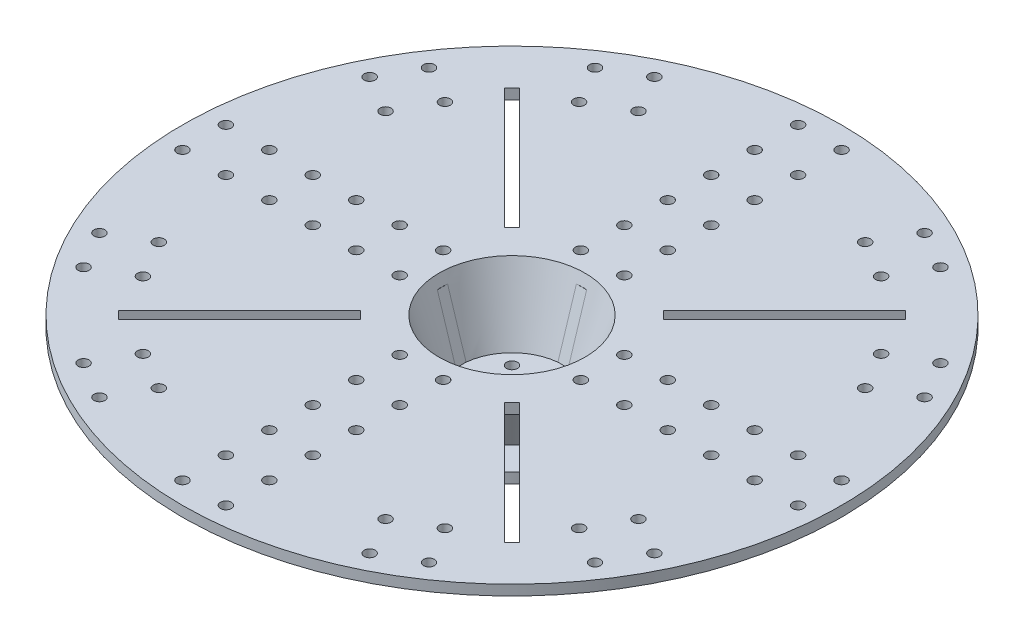
from build123d import *

# Parameters (mm, degrees)
BOSS_EXTRUDE2_DEPTH          = 3
CIRPATTERN2_COUNT            = 4
CUT_EXTRUDE3_DEPTH           = 6
CIRPATTERN4_COUNT            = 4
SKETCH7_W                    = 6
SKETCH7_H                    = 6
CUT_EXTRUDE4_DEPTH           = 34.25
SKETCH8_R                    = 3.175
CUT_EXTRUDE5_DEPTH           = 276.405074148
SKETCH11_R                   = 3.2
CUT_EXTRUDE6_DEPTH           = 276.405074148
LPATTERN2_COUNT              = 2
LPATTERN2_PITCH              = 25.4
LPATTERN2_COUNT_DIR2         = 6
LPATTERN2_PITCH_DIR2         = 25.4
CIRPATTERN5_COUNT            = 4
CIRPATTERN5_COPY_1_SKETCH_R  = 3.2
CIRPATTERN5_COPY_1_DEPTH     = 276.405074148
CIRPATTERN5_COPY_2_SKETCH_R  = 3.2
CIRPATTERN5_COPY_2_DEPTH     = 276.405074148
CIRPATTERN5_COPY_3_SKETCH_R  = 3.2
CIRPATTERN5_COPY_3_DEPTH     = 276.405074148
CIRPATTERN5_COPY_4_SKETCH_R  = 3.2
CIRPATTERN5_COPY_4_DEPTH     = 276.405074148
CIRPATTERN5_COPY_5_SKETCH_R  = 3.2
CIRPATTERN5_COPY_5_DEPTH     = 276.405074148
CIRPATTERN5_COPY_6_SKETCH_R  = 3.2
CIRPATTERN5_COPY_6_DEPTH     = 276.405074148
CIRPATTERN5_COPY_7_SKETCH_R  = 3.2
CIRPATTERN5_COPY_7_DEPTH     = 276.405074148
CIRPATTERN5_COPY_8_SKETCH_R  = 3.2
CIRPATTERN5_COPY_8_DEPTH     = 276.405074148
CIRPATTERN5_COPY_9_SKETCH_R  = 3.2
CIRPATTERN5_COPY_9_DEPTH     = 276.405074148
CIRPATTERN5_COPY_10_SKETCH_R = 3.2
CIRPATTERN5_COPY_10_DEPTH    = 276.405074148
CIRPATTERN5_COPY_11_SKETCH_R = 3.2
CIRPATTERN5_COPY_11_DEPTH    = 276.405074148
CIRPATTERN5_COPY_12_SKETCH_R = 3.2
CIRPATTERN5_COPY_12_DEPTH    = 276.405074148
CIRPATTERN5_COPY_13_SKETCH_R = 3.2
CIRPATTERN5_COPY_13_DEPTH    = 276.405074148
CIRPATTERN5_COPY_14_SKETCH_R = 3.2
CIRPATTERN5_COPY_14_DEPTH    = 276.405074148
CIRPATTERN5_COPY_15_SKETCH_R = 3.2
CIRPATTERN5_COPY_15_DEPTH    = 276.405074148
CIRPATTERN5_COPY_16_SKETCH_R = 3.2
CIRPATTERN5_COPY_16_DEPTH    = 276.405074148
CIRPATTERN5_COPY_17_SKETCH_R = 3.2
CIRPATTERN5_COPY_17_DEPTH    = 276.405074148
CIRPATTERN5_COPY_18_SKETCH_R = 3.2
CIRPATTERN5_COPY_18_DEPTH    = 276.405074148
CIRPATTERN5_COPY_19_SKETCH_R = 3.2
CIRPATTERN5_COPY_19_DEPTH    = 276.405074148
CIRPATTERN5_COPY_20_SKETCH_R = 3.2
CIRPATTERN5_COPY_20_DEPTH    = 276.405074148
CIRPATTERN5_COPY_21_SKETCH_R = 3.2
CIRPATTERN5_COPY_21_DEPTH    = 276.405074148
CIRPATTERN5_COPY_22_SKETCH_R = 3.2
CIRPATTERN5_COPY_22_DEPTH    = 276.405074148
CIRPATTERN5_COPY_23_SKETCH_R = 3.2
CIRPATTERN5_COPY_23_DEPTH    = 276.405074148
CIRPATTERN5_COPY_24_SKETCH_R = 3.2
CIRPATTERN5_COPY_24_DEPTH    = 276.405074148
CIRPATTERN5_COPY_25_SKETCH_R = 3.2
CIRPATTERN5_COPY_25_DEPTH    = 276.405074148
CIRPATTERN5_COPY_26_SKETCH_R = 3.2
CIRPATTERN5_COPY_26_DEPTH    = 276.405074148
CIRPATTERN5_COPY_27_SKETCH_R = 3.2
CIRPATTERN5_COPY_27_DEPTH    = 276.405074148
CIRPATTERN5_COPY_28_SKETCH_R = 3.2
CIRPATTERN5_COPY_28_DEPTH    = 276.405074148
CIRPATTERN5_COPY_29_SKETCH_R = 3.2
CIRPATTERN5_COPY_29_DEPTH    = 276.405074148
CIRPATTERN5_COPY_30_SKETCH_R = 3.2
CIRPATTERN5_COPY_30_DEPTH    = 276.405074148
CIRPATTERN5_COPY_31_SKETCH_R = 3.2
CIRPATTERN5_COPY_31_DEPTH    = 276.405074148
CIRPATTERN5_COPY_32_SKETCH_R = 3.2
CIRPATTERN5_COPY_32_DEPTH    = 276.405074148
CIRPATTERN5_COPY_33_SKETCH_R = 3.2
CIRPATTERN5_COPY_33_DEPTH    = 276.405074148
SKETCH17_R                   = 3.2
CUT_EXTRUDE7_DEPTH           = 277.345716208
LPATTERN3_COUNT              = 2
LPATTERN3_PITCH              = 25.4
LPATTERN3_COUNT_DIR2         = 2
LPATTERN3_PITCH_DIR2         = 25.4
MIRROR1_COPY_1_SKETCH_R      = 3.2
MIRROR1_COPY_1_DEPTH         = 277.345716208
MIRROR1_COPY_2_SKETCH_R      = 3.2
MIRROR1_COPY_2_DEPTH         = 277.345716208
MIRROR1_COPY_3_SKETCH_R      = 3.2
MIRROR1_COPY_3_DEPTH         = 277.345716208
MIRROR2_COPY_1_SKETCH_R      = 3.2
MIRROR2_COPY_1_DEPTH         = 277.345716208
MIRROR2_COPY_2_SKETCH_R      = 3.2
MIRROR2_COPY_2_DEPTH         = 277.345716208
MIRROR2_COPY_3_SKETCH_R      = 3.2
MIRROR2_COPY_3_DEPTH         = 277.345716208
MIRROR2_COPY_4_SKETCH_R      = 3.2
MIRROR2_COPY_4_DEPTH         = 277.345716208
MIRROR2_COPY_5_SKETCH_R      = 3.2
MIRROR2_COPY_5_DEPTH         = 277.345716208
MIRROR2_COPY_6_SKETCH_R      = 3.2
MIRROR2_COPY_6_DEPTH         = 277.345716208
MIRROR2_COPY_7_SKETCH_R      = 3.2
MIRROR2_COPY_7_DEPTH         = 277.345716208
CUT_EXTRUDE8_REACH           = 278.346
CIRPATTERN6_COUNT            = 4
SKETCH23_R                   = 3.2
CUT_EXTRUDE9_DEPTH           = 5.952869
CIRPATTERN7_COUNT            = 2
CIRPATTERN7_ANGLE            = 30
CIRPATTERN8_COUNT            = 4
CIRPATTERN8_COPY_1_SKETCH_R  = 3.2
CIRPATTERN8_COPY_1_DEPTH     = 5.952869
CIRPATTERN8_COPY_2_SKETCH_R  = 3.2
CIRPATTERN8_COPY_2_DEPTH     = 5.952869
CIRPATTERN8_COPY_3_SKETCH_R  = 3.2
CIRPATTERN8_COPY_3_DEPTH     = 5.952869
SKETCH26_R                   = 3.2
CUT_EXTRUDE10_DEPTH          = 277.345716208
LPATTERN4_COUNT              = 2
LPATTERN4_PITCH              = 25.4
LPATTERN4_COUNT_DIR2         = 2
LPATTERN4_PITCH_DIR2         = 25.4
MIRROR3_COPY_1_SKETCH_R      = 3.2
MIRROR3_COPY_1_DEPTH         = 277.345716208
MIRROR3_COPY_2_SKETCH_R      = 3.2
MIRROR3_COPY_2_DEPTH         = 277.345716208
MIRROR3_COPY_3_SKETCH_R      = 3.2
MIRROR3_COPY_3_DEPTH         = 277.345716208
MIRROR4_COPY_1_SKETCH_R      = 3.2
MIRROR4_COPY_1_DEPTH         = 277.345716208
MIRROR4_COPY_2_SKETCH_R      = 3.2
MIRROR4_COPY_2_DEPTH         = 277.345716208
MIRROR4_COPY_3_SKETCH_R      = 3.2
MIRROR4_COPY_3_DEPTH         = 277.345716208
MIRROR4_COPY_4_SKETCH_R      = 3.2
MIRROR4_COPY_4_DEPTH         = 277.345716208
MIRROR4_COPY_5_SKETCH_R      = 3.2
MIRROR4_COPY_5_DEPTH         = 277.345716208
MIRROR4_COPY_6_SKETCH_R      = 3.2
MIRROR4_COPY_6_DEPTH         = 277.345716208
MIRROR4_COPY_7_SKETCH_R      = 3.2
MIRROR4_COPY_7_DEPTH         = 277.345716208
CUT_EXTRUDE11_REACH          = 278.346
SKETCH27_R                   = 3.2
CIRPATTERN9_COUNT            = 4
CUT_EXTRUDE12_REACH          = 280.445
SKETCH28_W                   = 56
SKETCH28_H                   = 6.4
CIRPATTERN10_COUNT           = 4


with BuildPart() as part:
    # Sketch1 → Revolve2 (revolve)
    with BuildSketch(Plane.XY, mode=Mode.PRIVATE) as revolve2_sk:
        Polygon((0, -40.25), (0, -46.25), (55.5, -46.25), (55.5, -40.29713119), (36.117911549, -40.29713119), (46.896841146, -6), (192.649801929, -6), (192.649801929, 0), (42.649801929, 0), (30, -40.25), align=None)
    revolve(revolve2_sk.sketch.rotate(Axis((0, -40.25, 0), (0, -1, 0)), 90), axis=Axis((0, -40.25, 0), (0, -1, 0)))

    # Sketch3 → Boss-Extrude2 (add, symmetric)
    with BuildSketch(Plane.XY):
        Polygon((55.5, -40.29713119), (192.649801929, -6), (0, -6), (0, -40.29713119), align=None)
    boss_extrude2 = extrude(amount=BOSS_EXTRUDE2_DEPTH, both=True)

    # CirPattern2: Boss-Extrude2 ×4 about axis
    cirpattern2_axis = Axis((0, 0, 0), (0, 1, 0))
    for i in range(1, CIRPATTERN2_COUNT):
        add(boss_extrude2.rotate(cirpattern2_axis, i * 360 / CIRPATTERN2_COUNT))

    # Sketch6 → Cut-Extrude3 (cut)
    with BuildSketch(Plane.XY.offset(3)):
        Polygon((-3, -6), (-40.653576086, -6), (-29.849623113, -40.25), (-3, -40.25), align=None)
    cut_extrude3 = extrude(amount=-CUT_EXTRUDE3_DEPTH, mode=Mode.SUBTRACT)

    # CirPattern4: Cut-Extrude3 ×4 about axis
    cirpattern4_axis = Axis((0, 0, 0), (0, 1, 0))
    for i in range(1, CIRPATTERN4_COUNT):
        add(cut_extrude3.rotate(cirpattern4_axis, i * 360 / CIRPATTERN4_COUNT), mode=Mode.SUBTRACT)

    # Sketch7 → Cut-Extrude4 (cut)
    with BuildSketch(Plane(origin=(0, -6, 0), x_dir=(1, 0, 0), z_dir=(0, 1, 0))):
        Rectangle(SKETCH7_W, SKETCH7_H)
    extrude(amount=-CUT_EXTRUDE4_DEPTH, mode=Mode.SUBTRACT)

    # Sketch8 → Cut-Extrude5 (cut, through all)
    with BuildSketch(Plane(origin=(0, -40.25, 0), x_dir=(1, 0, 0), z_dir=(0, 1, 0))):
        with Locations(Location((0, 0, 0), (0, 0, 180))):
            Circle(SKETCH8_R)
    extrude(amount=-CUT_EXTRUDE5_DEPTH, mode=Mode.SUBTRACT)

    # Sketch11 → Cut-Extrude6 (cut, through all)
    with BuildSketch(Plane.XZ.offset(6)):
        with Locations((-12.7, 179.949801929)):
            Circle(SKETCH11_R)
    cut_extrude6 = extrude(amount=-CUT_EXTRUDE6_DEPTH, mode=Mode.SUBTRACT)

    # LPattern2: Cut-Extrude6 2 × 6
    with Locations(*[(i * LPATTERN2_PITCH, 0, -j * LPATTERN2_PITCH_DIR2) for i in range(LPATTERN2_COUNT) for j in range(LPATTERN2_COUNT_DIR2) if (i, j) != (0, 0)]):
        add(cut_extrude6, mode=Mode.SUBTRACT)

    # CirPattern5: Cut-Extrude6 ×4 about axis
    cirpattern5_axis = Axis((0, 0, 0), (0, 1, 0))
    for i in range(1, CIRPATTERN5_COUNT):
        add(cut_extrude6.rotate(cirpattern5_axis, i * 360 / CIRPATTERN5_COUNT), mode=Mode.SUBTRACT)

    # CirPattern5 copy 1 sketch → CirPattern5 copy 1 (cut, through all)
    with BuildSketch(Plane(origin=(-25.4, -6, 0), x_dir=(0, 0, -1), z_dir=(0, -1, 0))):
        with Locations((-12.7, 179.949801929)):
            Circle(CIRPATTERN5_COPY_1_SKETCH_R)
    extrude(amount=-CIRPATTERN5_COPY_1_DEPTH, mode=Mode.SUBTRACT)

    # CirPattern5 copy 2 sketch → CirPattern5 copy 2 (cut, through all)
    with BuildSketch(Plane(origin=(0, -6, 25.4), x_dir=(-1, 0, 0), z_dir=(0, -1, 0))):
        with Locations((-12.7, 179.949801929)):
            Circle(CIRPATTERN5_COPY_2_SKETCH_R)
    extrude(amount=-CIRPATTERN5_COPY_2_DEPTH, mode=Mode.SUBTRACT)

    # CirPattern5 copy 3 sketch → CirPattern5 copy 3 (cut, through all)
    with BuildSketch(Plane(origin=(25.4, -6, 0), x_dir=(0, 0, 1), z_dir=(0, -1, 0))):
        with Locations((-12.7, 179.949801929)):
            Circle(CIRPATTERN5_COPY_3_SKETCH_R)
    extrude(amount=-CIRPATTERN5_COPY_3_DEPTH, mode=Mode.SUBTRACT)

    # CirPattern5 copy 4 sketch → CirPattern5 copy 4 (cut, through all)
    with BuildSketch(Plane(origin=(-50.8, -6, 0), x_dir=(0, 0, -1), z_dir=(0, -1, 0))):
        with Locations((-12.7, 179.949801929)):
            Circle(CIRPATTERN5_COPY_4_SKETCH_R)
    extrude(amount=-CIRPATTERN5_COPY_4_DEPTH, mode=Mode.SUBTRACT)

    # CirPattern5 copy 5 sketch → CirPattern5 copy 5 (cut, through all)
    with BuildSketch(Plane(origin=(0, -6, 50.8), x_dir=(-1, 0, 0), z_dir=(0, -1, 0))):
        with Locations((-12.7, 179.949801929)):
            Circle(CIRPATTERN5_COPY_5_SKETCH_R)
    extrude(amount=-CIRPATTERN5_COPY_5_DEPTH, mode=Mode.SUBTRACT)

    # CirPattern5 copy 6 sketch → CirPattern5 copy 6 (cut, through all)
    with BuildSketch(Plane(origin=(50.8, -6, 0), x_dir=(0, 0, 1), z_dir=(0, -1, 0))):
        with Locations((-12.7, 179.949801929)):
            Circle(CIRPATTERN5_COPY_6_SKETCH_R)
    extrude(amount=-CIRPATTERN5_COPY_6_DEPTH, mode=Mode.SUBTRACT)

    # CirPattern5 copy 7 sketch → CirPattern5 copy 7 (cut, through all)
    with BuildSketch(Plane(origin=(-76.2, -6, 0), x_dir=(0, 0, -1), z_dir=(0, -1, 0))):
        with Locations((-12.7, 179.949801929)):
            Circle(CIRPATTERN5_COPY_7_SKETCH_R)
    extrude(amount=-CIRPATTERN5_COPY_7_DEPTH, mode=Mode.SUBTRACT)

    # CirPattern5 copy 8 sketch → CirPattern5 copy 8 (cut, through all)
    with BuildSketch(Plane(origin=(0, -6, 76.2), x_dir=(-1, 0, 0), z_dir=(0, -1, 0))):
        with Locations((-12.7, 179.949801929)):
            Circle(CIRPATTERN5_COPY_8_SKETCH_R)
    extrude(amount=-CIRPATTERN5_COPY_8_DEPTH, mode=Mode.SUBTRACT)

    # CirPattern5 copy 9 sketch → CirPattern5 copy 9 (cut, through all)
    with BuildSketch(Plane(origin=(76.2, -6, 0), x_dir=(0, 0, 1), z_dir=(0, -1, 0))):
        with Locations((-12.7, 179.949801929)):
            Circle(CIRPATTERN5_COPY_9_SKETCH_R)
    extrude(amount=-CIRPATTERN5_COPY_9_DEPTH, mode=Mode.SUBTRACT)

    # CirPattern5 copy 10 sketch → CirPattern5 copy 10 (cut, through all)
    with BuildSketch(Plane(origin=(-101.6, -6, 0), x_dir=(0, 0, -1), z_dir=(0, -1, 0))):
        with Locations((-12.7, 179.949801929)):
            Circle(CIRPATTERN5_COPY_10_SKETCH_R)
    extrude(amount=-CIRPATTERN5_COPY_10_DEPTH, mode=Mode.SUBTRACT)

    # CirPattern5 copy 11 sketch → CirPattern5 copy 11 (cut, through all)
    with BuildSketch(Plane(origin=(0, -6, 101.6), x_dir=(-1, 0, 0), z_dir=(0, -1, 0))):
        with Locations((-12.7, 179.949801929)):
            Circle(CIRPATTERN5_COPY_11_SKETCH_R)
    extrude(amount=-CIRPATTERN5_COPY_11_DEPTH, mode=Mode.SUBTRACT)

    # CirPattern5 copy 12 sketch → CirPattern5 copy 12 (cut, through all)
    with BuildSketch(Plane(origin=(101.6, -6, 0), x_dir=(0, 0, 1), z_dir=(0, -1, 0))):
        with Locations((-12.7, 179.949801929)):
            Circle(CIRPATTERN5_COPY_12_SKETCH_R)
    extrude(amount=-CIRPATTERN5_COPY_12_DEPTH, mode=Mode.SUBTRACT)

    # CirPattern5 copy 13 sketch → CirPattern5 copy 13 (cut, through all)
    with BuildSketch(Plane(origin=(-127, -6, 0), x_dir=(0, 0, -1), z_dir=(0, -1, 0))):
        with Locations((-12.7, 179.949801929)):
            Circle(CIRPATTERN5_COPY_13_SKETCH_R)
    extrude(amount=-CIRPATTERN5_COPY_13_DEPTH, mode=Mode.SUBTRACT)

    # CirPattern5 copy 14 sketch → CirPattern5 copy 14 (cut, through all)
    with BuildSketch(Plane(origin=(0, -6, 127), x_dir=(-1, 0, 0), z_dir=(0, -1, 0))):
        with Locations((-12.7, 179.949801929)):
            Circle(CIRPATTERN5_COPY_14_SKETCH_R)
    extrude(amount=-CIRPATTERN5_COPY_14_DEPTH, mode=Mode.SUBTRACT)

    # CirPattern5 copy 15 sketch → CirPattern5 copy 15 (cut, through all)
    with BuildSketch(Plane(origin=(127, -6, 0), x_dir=(0, 0, 1), z_dir=(0, -1, 0))):
        with Locations((-12.7, 179.949801929)):
            Circle(CIRPATTERN5_COPY_15_SKETCH_R)
    extrude(amount=-CIRPATTERN5_COPY_15_DEPTH, mode=Mode.SUBTRACT)

    # CirPattern5 copy 16 sketch → CirPattern5 copy 16 (cut, through all)
    with BuildSketch(Plane(origin=(0, -6, -25.4), x_dir=(0, 0, -1), z_dir=(0, -1, 0))):
        with Locations((-12.7, 179.949801929)):
            Circle(CIRPATTERN5_COPY_16_SKETCH_R)
    extrude(amount=-CIRPATTERN5_COPY_16_DEPTH, mode=Mode.SUBTRACT)

    # CirPattern5 copy 17 sketch → CirPattern5 copy 17 (cut, through all)
    with BuildSketch(Plane(origin=(-25.4, -6, 0), x_dir=(-1, 0, 0), z_dir=(0, -1, 0))):
        with Locations((-12.7, 179.949801929)):
            Circle(CIRPATTERN5_COPY_17_SKETCH_R)
    extrude(amount=-CIRPATTERN5_COPY_17_DEPTH, mode=Mode.SUBTRACT)

    # CirPattern5 copy 18 sketch → CirPattern5 copy 18 (cut, through all)
    with BuildSketch(Plane(origin=(0, -6, 25.4), x_dir=(0, 0, 1), z_dir=(0, -1, 0))):
        with Locations((-12.7, 179.949801929)):
            Circle(CIRPATTERN5_COPY_18_SKETCH_R)
    extrude(amount=-CIRPATTERN5_COPY_18_DEPTH, mode=Mode.SUBTRACT)

    # CirPattern5 copy 19 sketch → CirPattern5 copy 19 (cut, through all)
    with BuildSketch(Plane(origin=(-25.4, -6, -25.4), x_dir=(0, 0, -1), z_dir=(0, -1, 0))):
        with Locations((-12.7, 179.949801929)):
            Circle(CIRPATTERN5_COPY_19_SKETCH_R)
    extrude(amount=-CIRPATTERN5_COPY_19_DEPTH, mode=Mode.SUBTRACT)

    # CirPattern5 copy 20 sketch → CirPattern5 copy 20 (cut, through all)
    with BuildSketch(Plane(origin=(-25.4, -6, 25.4), x_dir=(-1, 0, 0), z_dir=(0, -1, 0))):
        with Locations((-12.7, 179.949801929)):
            Circle(CIRPATTERN5_COPY_20_SKETCH_R)
    extrude(amount=-CIRPATTERN5_COPY_20_DEPTH, mode=Mode.SUBTRACT)

    # CirPattern5 copy 21 sketch → CirPattern5 copy 21 (cut, through all)
    with BuildSketch(Plane(origin=(25.4, -6, 25.4), x_dir=(0, 0, 1), z_dir=(0, -1, 0))):
        with Locations((-12.7, 179.949801929)):
            Circle(CIRPATTERN5_COPY_21_SKETCH_R)
    extrude(amount=-CIRPATTERN5_COPY_21_DEPTH, mode=Mode.SUBTRACT)

    # CirPattern5 copy 22 sketch → CirPattern5 copy 22 (cut, through all)
    with BuildSketch(Plane(origin=(-50.8, -6, -25.4), x_dir=(0, 0, -1), z_dir=(0, -1, 0))):
        with Locations((-12.7, 179.949801929)):
            Circle(CIRPATTERN5_COPY_22_SKETCH_R)
    extrude(amount=-CIRPATTERN5_COPY_22_DEPTH, mode=Mode.SUBTRACT)

    # CirPattern5 copy 23 sketch → CirPattern5 copy 23 (cut, through all)
    with BuildSketch(Plane(origin=(-25.4, -6, 50.8), x_dir=(-1, 0, 0), z_dir=(0, -1, 0))):
        with Locations((-12.7, 179.949801929)):
            Circle(CIRPATTERN5_COPY_23_SKETCH_R)
    extrude(amount=-CIRPATTERN5_COPY_23_DEPTH, mode=Mode.SUBTRACT)

    # CirPattern5 copy 24 sketch → CirPattern5 copy 24 (cut, through all)
    with BuildSketch(Plane(origin=(50.8, -6, 25.4), x_dir=(0, 0, 1), z_dir=(0, -1, 0))):
        with Locations((-12.7, 179.949801929)):
            Circle(CIRPATTERN5_COPY_24_SKETCH_R)
    extrude(amount=-CIRPATTERN5_COPY_24_DEPTH, mode=Mode.SUBTRACT)

    # CirPattern5 copy 25 sketch → CirPattern5 copy 25 (cut, through all)
    with BuildSketch(Plane(origin=(-76.2, -6, -25.4), x_dir=(0, 0, -1), z_dir=(0, -1, 0))):
        with Locations((-12.7, 179.949801929)):
            Circle(CIRPATTERN5_COPY_25_SKETCH_R)
    extrude(amount=-CIRPATTERN5_COPY_25_DEPTH, mode=Mode.SUBTRACT)

    # CirPattern5 copy 26 sketch → CirPattern5 copy 26 (cut, through all)
    with BuildSketch(Plane(origin=(-25.4, -6, 76.2), x_dir=(-1, 0, 0), z_dir=(0, -1, 0))):
        with Locations((-12.7, 179.949801929)):
            Circle(CIRPATTERN5_COPY_26_SKETCH_R)
    extrude(amount=-CIRPATTERN5_COPY_26_DEPTH, mode=Mode.SUBTRACT)

    # CirPattern5 copy 27 sketch → CirPattern5 copy 27 (cut, through all)
    with BuildSketch(Plane(origin=(76.2, -6, 25.4), x_dir=(0, 0, 1), z_dir=(0, -1, 0))):
        with Locations((-12.7, 179.949801929)):
            Circle(CIRPATTERN5_COPY_27_SKETCH_R)
    extrude(amount=-CIRPATTERN5_COPY_27_DEPTH, mode=Mode.SUBTRACT)

    # CirPattern5 copy 28 sketch → CirPattern5 copy 28 (cut, through all)
    with BuildSketch(Plane(origin=(-101.6, -6, -25.4), x_dir=(0, 0, -1), z_dir=(0, -1, 0))):
        with Locations((-12.7, 179.949801929)):
            Circle(CIRPATTERN5_COPY_28_SKETCH_R)
    extrude(amount=-CIRPATTERN5_COPY_28_DEPTH, mode=Mode.SUBTRACT)

    # CirPattern5 copy 29 sketch → CirPattern5 copy 29 (cut, through all)
    with BuildSketch(Plane(origin=(-25.4, -6, 101.6), x_dir=(-1, 0, 0), z_dir=(0, -1, 0))):
        with Locations((-12.7, 179.949801929)):
            Circle(CIRPATTERN5_COPY_29_SKETCH_R)
    extrude(amount=-CIRPATTERN5_COPY_29_DEPTH, mode=Mode.SUBTRACT)

    # CirPattern5 copy 30 sketch → CirPattern5 copy 30 (cut, through all)
    with BuildSketch(Plane(origin=(101.6, -6, 25.4), x_dir=(0, 0, 1), z_dir=(0, -1, 0))):
        with Locations((-12.7, 179.949801929)):
            Circle(CIRPATTERN5_COPY_30_SKETCH_R)
    extrude(amount=-CIRPATTERN5_COPY_30_DEPTH, mode=Mode.SUBTRACT)

    # CirPattern5 copy 31 sketch → CirPattern5 copy 31 (cut, through all)
    with BuildSketch(Plane(origin=(-127, -6, -25.4), x_dir=(0, 0, -1), z_dir=(0, -1, 0))):
        with Locations((-12.7, 179.949801929)):
            Circle(CIRPATTERN5_COPY_31_SKETCH_R)
    extrude(amount=-CIRPATTERN5_COPY_31_DEPTH, mode=Mode.SUBTRACT)

    # CirPattern5 copy 32 sketch → CirPattern5 copy 32 (cut, through all)
    with BuildSketch(Plane(origin=(-25.4, -6, 127), x_dir=(-1, 0, 0), z_dir=(0, -1, 0))):
        with Locations((-12.7, 179.949801929)):
            Circle(CIRPATTERN5_COPY_32_SKETCH_R)
    extrude(amount=-CIRPATTERN5_COPY_32_DEPTH, mode=Mode.SUBTRACT)

    # CirPattern5 copy 33 sketch → CirPattern5 copy 33 (cut, through all)
    with BuildSketch(Plane(origin=(127, -6, 25.4), x_dir=(0, 0, 1), z_dir=(0, -1, 0))):
        with Locations((-12.7, 179.949801929)):
            Circle(CIRPATTERN5_COPY_33_SKETCH_R)
    extrude(amount=-CIRPATTERN5_COPY_33_DEPTH, mode=Mode.SUBTRACT)

    # Sketch17 → Cut-Extrude7 (cut, through all)
    with BuildSketch(Plane(origin=(0, 0, 0), x_dir=(1, 0, 0), z_dir=(0, 1, 0))):
        with Locations(Location((149.491099877, -100.973423593, 0), (0, 0, 180))):
            Circle(SKETCH17_R)
    cut_extrude7 = extrude(amount=-CUT_EXTRUDE7_DEPTH, mode=Mode.SUBTRACT)

    # LPattern3: Cut-Extrude7 2 × 2
    with Locations(*[Vector(-0.866025403784438, 0, -0.5000000000000012) * (i * LPATTERN3_PITCH) + Vector(0.500000000000003, 0, -0.866025403784437) * (j * LPATTERN3_PITCH_DIR2) for i in range(LPATTERN3_COUNT) for j in range(LPATTERN3_COUNT_DIR2) if (i, j) != (0, 0)]):
        add(cut_extrude7, mode=Mode.SUBTRACT)

    # Mirror1: Cut-Extrude7 across plane
    add(cut_extrude7.mirror(Plane(origin=(0, 0, 0), x_dir=(0, 0, 1), z_dir=(1, 0, 0))), mode=Mode.SUBTRACT)

    # Mirror1 copy 1 sketch → Mirror1 copy 1 (cut, through all)
    with BuildSketch(Plane(origin=(-12.7, 0, -21.997045256), x_dir=(-1, 0, 0), z_dir=(0, 1, 0))):
        with Locations((149.491099877, 100.973423593)):
            Circle(MIRROR1_COPY_1_SKETCH_R)
    extrude(amount=-MIRROR1_COPY_1_DEPTH, mode=Mode.SUBTRACT)

    # Mirror1 copy 2 sketch → Mirror1 copy 2 (cut, through all)
    with BuildSketch(Plane(origin=(21.997045256, 0, -12.7), x_dir=(-1, 0, 0), z_dir=(0, 1, 0))):
        with Locations((149.491099877, 100.973423593)):
            Circle(MIRROR1_COPY_2_SKETCH_R)
    extrude(amount=-MIRROR1_COPY_2_DEPTH, mode=Mode.SUBTRACT)

    # Mirror1 copy 3 sketch → Mirror1 copy 3 (cut, through all)
    with BuildSketch(Plane(origin=(9.297045256, 0, -34.697045256), x_dir=(-1, 0, 0), z_dir=(0, 1, 0))):
        with Locations((149.491099877, 100.973423593)):
            Circle(MIRROR1_COPY_3_SKETCH_R)
    extrude(amount=-MIRROR1_COPY_3_DEPTH, mode=Mode.SUBTRACT)

    # Mirror2: Cut-Extrude7 across plane
    add(cut_extrude7.mirror(Plane.XY), mode=Mode.SUBTRACT)

    # Mirror2 copy 1 sketch → Mirror2 copy 1 (cut, through all)
    with BuildSketch(Plane(origin=(12.7, 0, 21.997045256), x_dir=(1, 0, 0), z_dir=(0, 1, 0))):
        with Locations((149.491099877, 100.973423593)):
            Circle(MIRROR2_COPY_1_SKETCH_R)
    extrude(amount=-MIRROR2_COPY_1_DEPTH, mode=Mode.SUBTRACT)

    # Mirror2 copy 2 sketch → Mirror2 copy 2 (cut, through all)
    with BuildSketch(Plane(origin=(-21.997045256, 0, 12.7), x_dir=(1, 0, 0), z_dir=(0, 1, 0))):
        with Locations((149.491099877, 100.973423593)):
            Circle(MIRROR2_COPY_2_SKETCH_R)
    extrude(amount=-MIRROR2_COPY_2_DEPTH, mode=Mode.SUBTRACT)

    # Mirror2 copy 3 sketch → Mirror2 copy 3 (cut, through all)
    with BuildSketch(Plane(origin=(-9.297045256, 0, 34.697045256), x_dir=(1, 0, 0), z_dir=(0, 1, 0))):
        with Locations((149.491099877, 100.973423593)):
            Circle(MIRROR2_COPY_3_SKETCH_R)
    extrude(amount=-MIRROR2_COPY_3_DEPTH, mode=Mode.SUBTRACT)

    # Mirror2 copy 4 sketch → Mirror2 copy 4 (cut, through all)
    with BuildSketch(Plane(origin=(0, 0, 0), x_dir=(-1, 0, 0), z_dir=(0, 1, 0))):
        with Locations(Location((149.491099877, -100.973423593, 0), (0, 0, 180))):
            Circle(MIRROR2_COPY_4_SKETCH_R)
    extrude(amount=-MIRROR2_COPY_4_DEPTH, mode=Mode.SUBTRACT)

    # Mirror2 copy 5 sketch → Mirror2 copy 5 (cut, through all)
    with BuildSketch(Plane(origin=(-12.7, 0, 21.997045256), x_dir=(-1, 0, 0), z_dir=(0, 1, 0))):
        with Locations(Location((149.491099877, -100.973423593, 0), (0, 0, 180))):
            Circle(MIRROR2_COPY_5_SKETCH_R)
    extrude(amount=-MIRROR2_COPY_5_DEPTH, mode=Mode.SUBTRACT)

    # Mirror2 copy 6 sketch → Mirror2 copy 6 (cut, through all)
    with BuildSketch(Plane(origin=(21.997045256, 0, 12.7), x_dir=(-1, 0, 0), z_dir=(0, 1, 0))):
        with Locations(Location((149.491099877, -100.973423593, 0), (0, 0, 180))):
            Circle(MIRROR2_COPY_6_SKETCH_R)
    extrude(amount=-MIRROR2_COPY_6_DEPTH, mode=Mode.SUBTRACT)

    # Mirror2 copy 7 sketch → Mirror2 copy 7 (cut, through all)
    with BuildSketch(Plane(origin=(9.297045256, 0, 34.697045256), x_dir=(-1, 0, 0), z_dir=(0, 1, 0))):
        with Locations(Location((149.491099877, -100.973423593, 0), (0, 0, 180))):
            Circle(MIRROR2_COPY_7_SKETCH_R)
    extrude(amount=-MIRROR2_COPY_7_DEPTH, mode=Mode.SUBTRACT)

    # Sketch19 → Cut-Extrude8 (cut, up to next)
    with BuildSketch(Plane(origin=(0, 0, 0), x_dir=(1, 0, 0), z_dir=(0, 1, 0)), mode=Mode.PRIVATE) as cut_extrude8_sk1:
        Polygon((117.273519603, 112.748036203), (112.748036203, 117.273519603), (42.037358084, 46.562841484), (46.562841484, 42.037358084), align=None)
    cut_extrude8_tool1 = extrude(cut_extrude8_sk1.sketch, amount=-CUT_EXTRUDE8_REACH, mode=Mode.PRIVATE) & part.part
    cut_extrude8 = cut_extrude8_tool1.solids().sort_by_distance((79.655439, 0, -79.655439))[0]
    add(cut_extrude8, mode=Mode.SUBTRACT)

    # CirPattern6: Cut-Extrude8 ×4 about axis
    cirpattern6_axis = Axis((0, 0, 0), (0, 1, 0))
    for i in range(1, CIRPATTERN6_COUNT):
        add(cut_extrude8.rotate(cirpattern6_axis, i * 360 / CIRPATTERN6_COUNT), mode=Mode.SUBTRACT)

    # Sketch23 → Cut-Extrude9 (cut)
    with BuildSketch(Plane.XZ.offset(46.25)):
        with Locations(Location((23, -39.837168574, 0), (0, 0, 270))):
            Circle(SKETCH23_R)
    cut_extrude9 = extrude(amount=-CUT_EXTRUDE9_DEPTH, mode=Mode.SUBTRACT)

    # CirPattern7: Cut-Extrude9 ×2 about axis
    cirpattern7_axis = Axis((0, 0, 0), (0, -1, 0))
    for i in range(1, CIRPATTERN7_COUNT):
        add(cut_extrude9.rotate(cirpattern7_axis, i * CIRPATTERN7_ANGLE / (CIRPATTERN7_COUNT - 1)), mode=Mode.SUBTRACT)

    # CirPattern8: Cut-Extrude9 ×4 about axis
    cirpattern8_axis = Axis((0, 0, 0), (0, 1, 0))
    for i in range(1, CIRPATTERN8_COUNT):
        add(cut_extrude9.rotate(cirpattern8_axis, i * 360 / CIRPATTERN8_COUNT), mode=Mode.SUBTRACT)

    # CirPattern8 copy 1 sketch → CirPattern8 copy 1 (cut)
    with BuildSketch(Plane(origin=(0, -46.25, 0), x_dir=(0.5000000000000011, 0, -0.866025403784438), z_dir=(0, -1, 0))):
        with Locations(Location((23, -39.837168574, 0), (0, 0, 270))):
            Circle(CIRPATTERN8_COPY_1_SKETCH_R)
    extrude(amount=-CIRPATTERN8_COPY_1_DEPTH, mode=Mode.SUBTRACT)

    # CirPattern8 copy 2 sketch → CirPattern8 copy 2 (cut)
    with BuildSketch(Plane(origin=(0, -46.25, 0), x_dir=(-0.8660254037844379, 0, -0.5000000000000012), z_dir=(0, -1, 0))):
        with Locations(Location((23, -39.837168574, 0), (0, 0, 270))):
            Circle(CIRPATTERN8_COPY_2_SKETCH_R)
    extrude(amount=-CIRPATTERN8_COPY_2_DEPTH, mode=Mode.SUBTRACT)

    # CirPattern8 copy 3 sketch → CirPattern8 copy 3 (cut)
    with BuildSketch(Plane(origin=(0, -46.25, 0), x_dir=(-0.5000000000000012, 0, 0.8660254037844379), z_dir=(0, -1, 0))):
        with Locations(Location((23, -39.837168574, 0), (0, 0, 270))):
            Circle(CIRPATTERN8_COPY_3_SKETCH_R)
    extrude(amount=-CIRPATTERN8_COPY_3_DEPTH, mode=Mode.SUBTRACT)

    # Sketch26 → Cut-Extrude10 (cut, through all)
    with BuildSketch(Plane(origin=(0, 0, 0), x_dir=(1, 0, 0), z_dir=(0, 1, 0))):
        with Locations(Location((78.976378337, -162.191099877, 0), (0, 0, 180))):
            Circle(SKETCH26_R)
    cut_extrude10 = extrude(amount=-CUT_EXTRUDE10_DEPTH, mode=Mode.SUBTRACT)

    # LPattern4: Cut-Extrude10 2 × 2
    with Locations(*[Vector(-0.5000000000000012, 0, -0.866025403784438) * (i * LPATTERN4_PITCH) + Vector(0.866025403784439, 0, -0.4999999999999995) * (j * LPATTERN4_PITCH_DIR2) for i in range(LPATTERN4_COUNT) for j in range(LPATTERN4_COUNT_DIR2) if (i, j) != (0, 0)]):
        add(cut_extrude10, mode=Mode.SUBTRACT)

    # Mirror3: Cut-Extrude10 across plane
    add(cut_extrude10.mirror(Plane(origin=(0, 0, 0), x_dir=(0, 0, 1), z_dir=(1, 0, 0))), mode=Mode.SUBTRACT)

    # Mirror3 copy 1 sketch → Mirror3 copy 1 (cut, through all)
    with BuildSketch(Plane(origin=(-21.997045256, 0, -12.7), x_dir=(-1, 0, 0), z_dir=(0, 1, 0))):
        with Locations((78.976378337, 162.191099877)):
            Circle(MIRROR3_COPY_1_SKETCH_R)
    extrude(amount=-MIRROR3_COPY_1_DEPTH, mode=Mode.SUBTRACT)

    # Mirror3 copy 2 sketch → Mirror3 copy 2 (cut, through all)
    with BuildSketch(Plane(origin=(12.7, 0, -21.997045256), x_dir=(-1, 0, 0), z_dir=(0, 1, 0))):
        with Locations((78.976378337, 162.191099877)):
            Circle(MIRROR3_COPY_2_SKETCH_R)
    extrude(amount=-MIRROR3_COPY_2_DEPTH, mode=Mode.SUBTRACT)

    # Mirror3 copy 3 sketch → Mirror3 copy 3 (cut, through all)
    with BuildSketch(Plane(origin=(-9.297045256, 0, -34.697045256), x_dir=(-1, 0, 0), z_dir=(0, 1, 0))):
        with Locations((78.976378337, 162.191099877)):
            Circle(MIRROR3_COPY_3_SKETCH_R)
    extrude(amount=-MIRROR3_COPY_3_DEPTH, mode=Mode.SUBTRACT)

    # Mirror4: Cut-Extrude10 across plane
    add(cut_extrude10.mirror(Plane.XY), mode=Mode.SUBTRACT)

    # Mirror4 copy 1 sketch → Mirror4 copy 1 (cut, through all)
    with BuildSketch(Plane(origin=(21.997045256, 0, 12.7), x_dir=(1, 0, 0), z_dir=(0, 1, 0))):
        with Locations((78.976378337, 162.191099877)):
            Circle(MIRROR4_COPY_1_SKETCH_R)
    extrude(amount=-MIRROR4_COPY_1_DEPTH, mode=Mode.SUBTRACT)

    # Mirror4 copy 2 sketch → Mirror4 copy 2 (cut, through all)
    with BuildSketch(Plane(origin=(-12.7, 0, 21.997045256), x_dir=(1, 0, 0), z_dir=(0, 1, 0))):
        with Locations((78.976378337, 162.191099877)):
            Circle(MIRROR4_COPY_2_SKETCH_R)
    extrude(amount=-MIRROR4_COPY_2_DEPTH, mode=Mode.SUBTRACT)

    # Mirror4 copy 3 sketch → Mirror4 copy 3 (cut, through all)
    with BuildSketch(Plane(origin=(9.297045256, 0, 34.697045256), x_dir=(1, 0, 0), z_dir=(0, 1, 0))):
        with Locations((78.976378337, 162.191099877)):
            Circle(MIRROR4_COPY_3_SKETCH_R)
    extrude(amount=-MIRROR4_COPY_3_DEPTH, mode=Mode.SUBTRACT)

    # Mirror4 copy 4 sketch → Mirror4 copy 4 (cut, through all)
    with BuildSketch(Plane(origin=(0, 0, 0), x_dir=(-1, 0, 0), z_dir=(0, 1, 0))):
        with Locations(Location((78.976378337, -162.191099877, 0), (0, 0, 180))):
            Circle(MIRROR4_COPY_4_SKETCH_R)
    extrude(amount=-MIRROR4_COPY_4_DEPTH, mode=Mode.SUBTRACT)

    # Mirror4 copy 5 sketch → Mirror4 copy 5 (cut, through all)
    with BuildSketch(Plane(origin=(-21.997045256, 0, 12.7), x_dir=(-1, 0, 0), z_dir=(0, 1, 0))):
        with Locations(Location((78.976378337, -162.191099877, 0), (0, 0, 180))):
            Circle(MIRROR4_COPY_5_SKETCH_R)
    extrude(amount=-MIRROR4_COPY_5_DEPTH, mode=Mode.SUBTRACT)

    # Mirror4 copy 6 sketch → Mirror4 copy 6 (cut, through all)
    with BuildSketch(Plane(origin=(12.7, 0, 21.997045256), x_dir=(-1, 0, 0), z_dir=(0, 1, 0))):
        with Locations(Location((78.976378337, -162.191099877, 0), (0, 0, 180))):
            Circle(MIRROR4_COPY_6_SKETCH_R)
    extrude(amount=-MIRROR4_COPY_6_DEPTH, mode=Mode.SUBTRACT)

    # Mirror4 copy 7 sketch → Mirror4 copy 7 (cut, through all)
    with BuildSketch(Plane(origin=(-9.297045256, 0, 34.697045256), x_dir=(-1, 0, 0), z_dir=(0, 1, 0))):
        with Locations(Location((78.976378337, -162.191099877, 0), (0, 0, 180))):
            Circle(MIRROR4_COPY_7_SKETCH_R)
    extrude(amount=-MIRROR4_COPY_7_DEPTH, mode=Mode.SUBTRACT)

    # Sketch27 → Cut-Extrude11 (cut, up to next)
    with BuildSketch(Plane.XZ.offset(46.25), mode=Mode.PRIVATE) as cut_extrude11_sk1:
        with Locations((14.849242405, -14.849242405)):
            Circle(SKETCH27_R)
    cut_extrude11_tool1 = extrude(cut_extrude11_sk1.sketch, amount=-CUT_EXTRUDE11_REACH, mode=Mode.PRIVATE) & part.part
    cut_extrude11 = cut_extrude11_tool1.solids().sort_by_distance((14.849242, -46.25, -14.849242))[0]
    add(cut_extrude11, mode=Mode.SUBTRACT)

    # CirPattern9: Cut-Extrude11 ×4 about axis
    cirpattern9_axis = Axis((0, 0, 0), (0, 1, 0))
    for i in range(1, CIRPATTERN9_COUNT):
        add(cut_extrude11.rotate(cirpattern9_axis, i * 360 / CIRPATTERN9_COUNT), mode=Mode.SUBTRACT)

    # Sketch28 → Cut-Extrude12 (cut, up to next)
    with BuildSketch(Plane(origin=(3, 0, 0), x_dir=(0, 0, -1), z_dir=(1, 0, 0)), mode=Mode.PRIVATE) as cut_extrude12_sk1:
        with Locations((79, -15.6)):
            Rectangle(SKETCH28_W, SKETCH28_H)
    cut_extrude12_tool1 = extrude(cut_extrude12_sk1.sketch, amount=-CUT_EXTRUDE12_REACH, mode=Mode.PRIVATE) & part.part
    cut_extrude12 = cut_extrude12_tool1.solids().sort_by_distance((3, -15.6, -79))[0]
    add(cut_extrude12, mode=Mode.SUBTRACT)

    # CirPattern10: Cut-Extrude12 ×4 about axis
    cirpattern10_axis = Axis((0, 0, 0), (0, 1, 0))
    for i in range(1, CIRPATTERN10_COUNT):
        add(cut_extrude12.rotate(cirpattern10_axis, i * 360 / CIRPATTERN10_COUNT), mode=Mode.SUBTRACT)


solid = part.part
